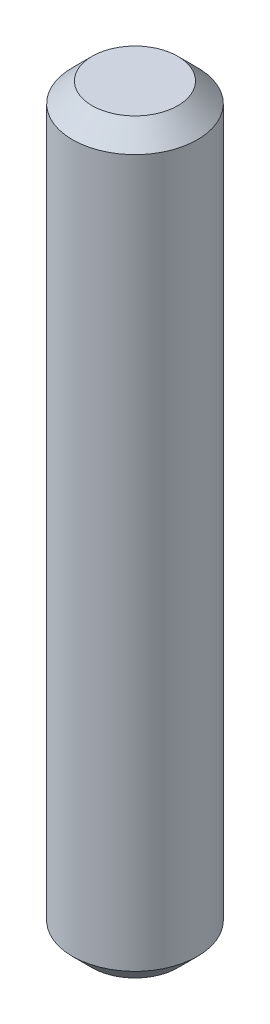
from build123d import *

# Parameters (mm, degrees)
SKETCH1_R           = 1.59
BOSS_EXTRUDE1_DEPTH = 9.5
CHAMFER1_SIZE       = 0.5


with BuildPart() as part:
    # Sketch1 → Boss-Extrude1 (new body, symmetric)
    with BuildSketch(Plane(origin=(0, 0, 0), x_dir=(1, 0, 0), z_dir=(0, 1, 0))):
        Circle(SKETCH1_R)
    extrude(amount=BOSS_EXTRUDE1_DEPTH, both=True)

    # Chamfer1
    chamfer1_edges = [part.edges().sort_by_distance(p)[0] for p in [
        (-1.59, -9.5, 0),
        (-1.59, 9.5, 0),
    ]]
    chamfer(chamfer1_edges, length=CHAMFER1_SIZE)


solid = part.part
